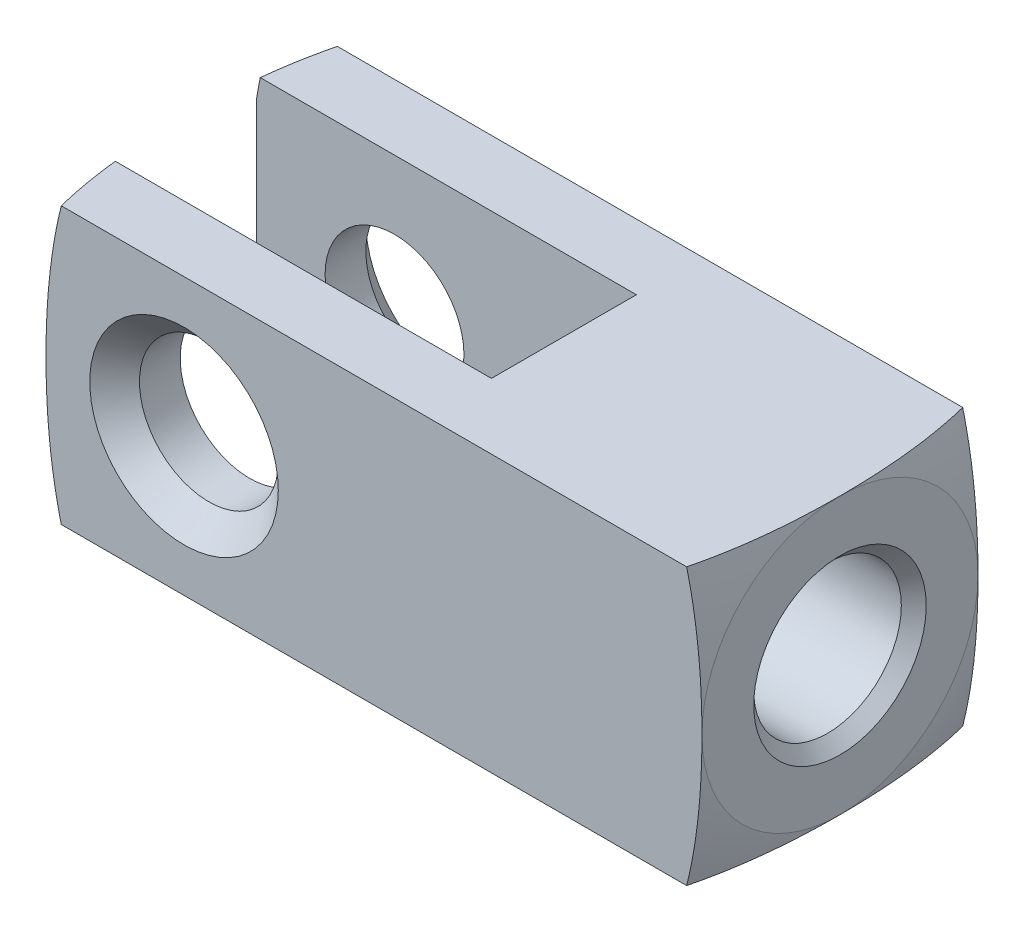
from build123d import *

# Parameters (mm, degrees)
BOSS_EXTRUDE1_DEPTH      = 6.35
BOSS_EXTRUDE1_DEPTH_BACK = 6.35
SKETCH1_W                = 30.1752
SKETCH1_H                = 12.7
CUT_EXTRUDE1_DEPTH       = 6.35
CUT_EXTRUDE1_DEPTH_BACK  = 6.35
SKETCH2_W                = 17.4752
SKETCH2_H                = 6.6675
HOLE1_D                  = 6.79196
HOLE1_DEPTH              = 11.176
HOLE1_CSINK_D            = 7.9375
HOLE1_CSINK_ANGLE        = 90
HOLE2_D                  = 6.79196
HOLE2_DEPTH              = 1.524


with BuildPart() as part:
    # Sketch1 → Boss-Extrude1 (new, two sides: drawn at the far end of the back side and taken through both)
    with BuildSketch(Plane.XY.offset(-BOSS_EXTRUDE1_DEPTH_BACK)):
        with Locations((8.7376, 0)):
            Rectangle(SKETCH1_W, SKETCH1_H)
    extrude(amount=BOSS_EXTRUDE1_DEPTH + BOSS_EXTRUDE1_DEPTH_BACK)

    # Sketch2 → Cut-Extrude1 (cut, two sides: drawn at the far end of the back side and taken through both)
    with BuildSketch(Plane(origin=(0, 0, 0), x_dir=(1, 0, 0), z_dir=(0, 1, 0)).offset(-CUT_EXTRUDE1_DEPTH_BACK)):
        with Locations((2.3876, 0)):
            Rectangle(SKETCH2_W, SKETCH2_H)
    extrude(amount=CUT_EXTRUDE1_DEPTH + CUT_EXTRUDE1_DEPTH_BACK, mode=Mode.SUBTRACT)

    # Hole1
    with Locations(Plane(origin=(23.8252, 0, 0), x_dir=(0, 0, -1), z_dir=(1, 0, 0))):
        with Locations((0, 0)):
            CounterSinkHole(HOLE1_D / 2, HOLE1_CSINK_D / 2, depth=HOLE1_DEPTH, counter_sink_angle=HOLE1_CSINK_ANGLE)

    # Hole2
    with Locations(Plane(origin=(12.6492, 0, 0), x_dir=(0, 0, -1), z_dir=(1, 0, 0))):
        with Locations((0, 0)):
            Hole(HOLE2_D / 2, depth=HOLE2_DEPTH)

    # Sketch7 → Cut-Revolve1 (revolve, cut)
    with BuildSketch(Plane(origin=(0, 0, 0), x_dir=(0, 0, -1), z_dir=(1, 0, 0))):
        Polygon((-6.35, 0), (-6.35, 4.33705), (-5.207, 3.19405), (5.207, 3.19405), (6.35, 4.33705), (6.35, 0), align=None)
    revolve(axis=Axis((0, 0, -6.35), (0, 0, 1)), mode=Mode.SUBTRACT)

    # Sketch8 → Cut-Revolve2 (revolve, cut)
    with BuildSketch(Plane.XY):
        with BuildLine():
            Line((23.8252, 0), (23.8252, 6.35))
            ThreePointArc((23.8252, 6.35), (22.869586956, 9.650754782), (21.2852, 12.7))
            Line((21.2852, 12.7), (30.1752, 12.7))
            Line((30.1752, 12.7), (30.1752, 0))
            Line((30.1752, 0), (23.8252, 0))
        make_face()
    revolve(axis=Axis((30.1752, 0, 0), (-1, 0, 0)), mode=Mode.SUBTRACT)

    # Sketch9 → Cut-Revolve3 (revolve, cut)
    with BuildSketch(Plane.XY):
        with BuildLine():
            Line((-12.7, 0), (-12.7, 12.7))
            Line((-12.7, 12.7), (-3.81, 12.7))
            ThreePointArc((-3.81, 12.7), (-5.394386956, 9.650754782), (-6.35, 6.35))
            Line((-6.35, 6.35), (-6.35, 0))
            Line((-6.35, 0), (-12.7, 0))
        make_face()
    revolve(axis=Axis((-6.35, 0, 0), (-1, 0, 0)), mode=Mode.SUBTRACT)


solid = part.part
